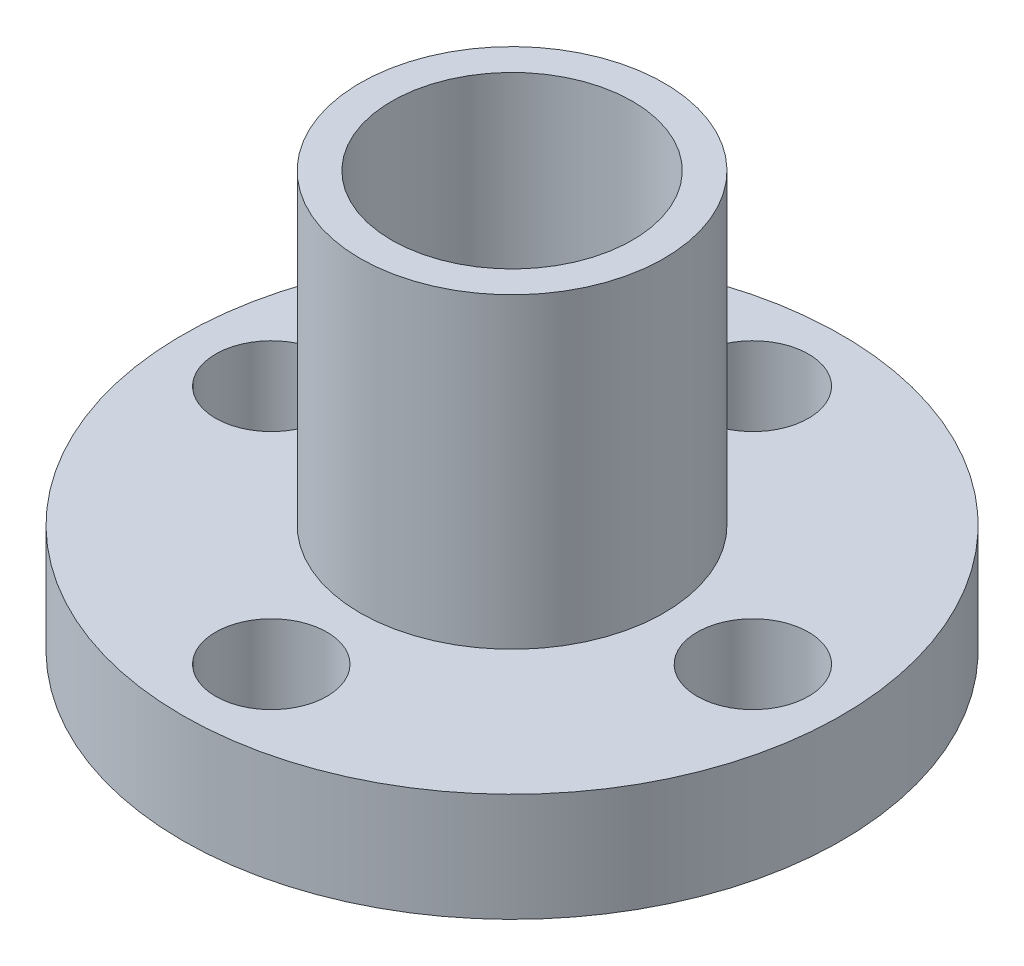
from build123d import *
from build123d.topology import SkipClean

# Parameters (mm, degrees)
SKETCH1_R               = 10.95
BOSS_EXTRUDE1_DEPTH     = 3.6
SKETCH2_R               = 5.05
SKETCH2_R_2             = 4
BOSS_EXTRUDE2_DEPTH     = 10.2
SKETCH3_R               = 5.05
SKETCH3_R_2             = 4
BOSS_EXTRUDE4_DEPTH     = 0.65
SKETCH4_R               = 1.85
SKETCH4_R_2             = 4
CUT_EXTRUDE1_DEPTH      = 11.2
CUT_EXTRUDE1_DEPTH_BACK = 5.25


with BuildPart() as part:
    # Sketch1 → Boss-Extrude1 (new body)
    with BuildSketch(Plane(origin=(0, 0, 0), x_dir=(1, 0, 0), z_dir=(0, 1, 0))):
        with Locations(Location((0, 0, 0), (0, 0, 270))):  # turned: the seam where the file's is
            Circle(SKETCH1_R)
    extrude(amount=BOSS_EXTRUDE1_DEPTH)

    # Sketch2 → Boss-Extrude2 (add)
    with BuildSketch(Plane(origin=(0, 3.6, 0), x_dir=(1, 0, 0), z_dir=(0, 1, 0))):
        with Locations(Location((0, 0, 0), (0, 0, 270))):  # turned: the seam where the file's is
            Circle(SKETCH2_R)
        with Locations(Location((0, 0, 0), (0, 0, 270))):  # turned: the seam where the file's is
            Circle(SKETCH2_R_2, mode=Mode.SUBTRACT)
    extrude(amount=BOSS_EXTRUDE2_DEPTH)

    # Sketch3 → Boss-Extrude4 (add)
    with BuildSketch(Plane.XZ):
        with Locations(Location((0, 0, 0), (0, 0, 90))):  # turned: the seam where the file's is
            Circle(SKETCH3_R)
        with Locations(Location((0, 0, 0), (0, 0, 90))):  # turned: the seam where the file's is
            Circle(SKETCH3_R_2, mode=Mode.SUBTRACT)
    extrude(amount=BOSS_EXTRUDE4_DEPTH)

    # Sketch4 → Cut-Extrude1 (cut, two sides)
    with SkipClean():  # keep this step's faces unmerged: merging them makes the solid invalid here
        with BuildSketch(Plane(origin=(0, 3.6, 0), x_dir=(1, 0, 0), z_dir=(0, 1, 0))) as cut_extrude1_sk:
            with Locations(Location((0, 8, 0), (0, 0, 270))):  # turned: the seam where the file's is
                Circle(SKETCH4_R)
            with Locations(Location((0, 0, 0), (0, 0, 90))):  # turned: the seam where the file's is
                Circle(SKETCH4_R_2)
            with Locations(Location((8, 0, 0), (0, 0, 270))):  # turned: the seam where the file's is
                Circle(SKETCH4_R)
            with Locations(Location((0, -8, 0), (0, 0, 270))):  # turned: the seam where the file's is
                Circle(SKETCH4_R)
            with Locations(Location((-8, 0, 0), (0, 0, 270))):  # turned: the seam where the file's is
                Circle(SKETCH4_R)
        extrude(amount=CUT_EXTRUDE1_DEPTH, mode=Mode.SUBTRACT)
        extrude(cut_extrude1_sk.sketch, amount=-CUT_EXTRUDE1_DEPTH_BACK, mode=Mode.SUBTRACT)


solid = part.part
